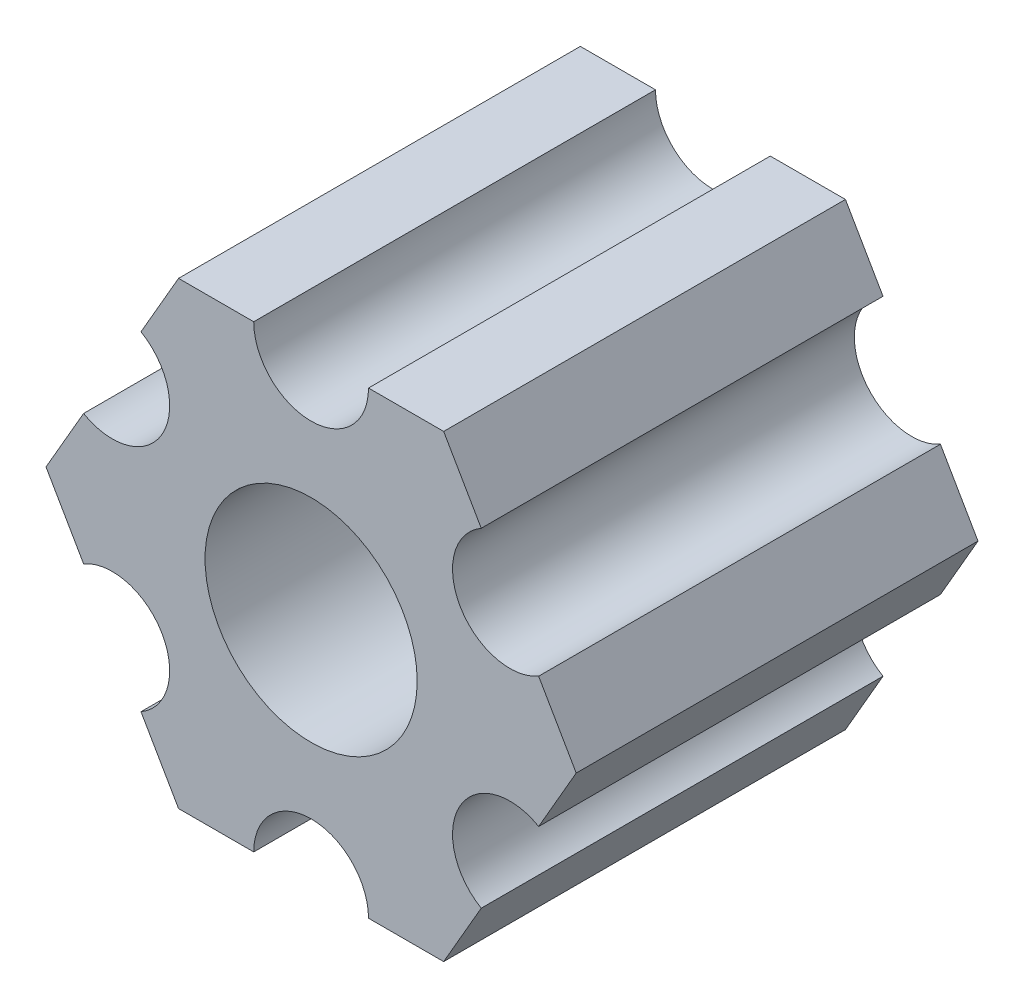
from build123d import *

# Parameters (mm, degrees)
SKETCH1_R           = 2.9337
BOSS_EXTRUDE1_DEPTH = 15.875
CUT_EXTRUDE1_DEPTH  = 4.7625


with BuildPart() as part:
    # Sketch1 → Boss-Extrude1 (new body)
    with BuildSketch(Plane(origin=(0, 0, 0), x_dir=(-1, 0, 0), z_dir=(0, 0, -1))):
        with BuildLine():
            Line((-4.70551159, -4.549815043), (-3.666174521, -6.349999904))
            Line((-3.666174521, -6.349999904), (-1.587500385, -6.349999904))
            ThreePointArc((-1.587500385, -6.349999904), (-3.85e-07, -4.762499904), (1.587499615, -6.349999904))
            Line((1.587499615, -6.349999904), (3.666173825, -6.349999904))
            Line((3.666173825, -6.349999904), (4.705510942, -4.54981524))
            ThreePointArc((4.705510942, -4.54981524), (4.124445629, -2.381249907), (6.293010962, -1.800184594))
            Line((6.293010962, -1.800184594), (7.332348079, 7e-08))
            Line((7.332348079, 7e-08), (6.293011217, 1.800184685))
            ThreePointArc((6.293011217, 1.800184685), (4.124445939, 2.381250203), (4.705511457, 4.549815481))
            Line((4.705511457, 4.549815481), (3.666174521, 6.350000222))
            Line((3.666174521, 6.350000222), (1.587500385, 6.350000222))
            ThreePointArc((1.587500385, 6.350000222), (3.85e-07, 4.762500222), (-1.587499615, 6.350000222))
            Line((-1.587499615, 6.350000222), (-3.666173825, 6.350000222))
            Line((-3.666173825, 6.350000222), (-4.705511038, 4.549815614))
            ThreePointArc((-4.705511038, 4.549815614), (-4.124445841, 2.38125025), (-6.293011205, 1.800185053))
            Line((-6.293011205, 1.800185053), (-7.332348419, 4.44e-07))
            Line((-7.332348419, 4.44e-07), (-6.293011423, -1.80018429))
            ThreePointArc((-6.293011423, -1.80018429), (-4.12444613, -2.38124975), (-4.70551159, -4.549815043))
        make_face()
        Circle(SKETCH1_R, mode=Mode.SUBTRACT)
    extrude(amount=-BOSS_EXTRUDE1_DEPTH)

    # Sketch3 → Cut-Extrude1 (cut)
    with BuildSketch(Plane.XY.offset(15.875)):
        with BuildLine():
            Line((-4.705511457, 4.549815481), (-3.666174521, 6.350000222))
            Line((-3.666174521, 6.350000222), (-1.587500385, 6.350000222))
            ThreePointArc((-1.587500385, 6.350000222), (-3.85e-07, 4.762500222), (1.587499615, 6.350000222))
            Line((1.587499615, 6.350000222), (3.666173825, 6.350000222))
            Line((3.666173825, 6.350000222), (4.705511038, 4.549815614))
            ThreePointArc((4.705511038, 4.549815614), (4.124445841, 2.38125025), (6.293011205, 1.800185053))
            Line((6.293011205, 1.800185053), (7.332348419, 4.44e-07))
            Line((7.332348419, 4.44e-07), (6.293011423, -1.80018429))
            ThreePointArc((6.293011423, -1.80018429), (4.12444613, -2.38124975), (4.70551159, -4.549815043))
            Line((4.70551159, -4.549815043), (3.666174521, -6.349999904))
            Line((3.666174521, -6.349999904), (1.587500385, -6.349999904))
            ThreePointArc((1.587500385, -6.349999904), (3.85e-07, -4.762499904), (-1.587499615, -6.349999904))
            Line((-1.587499615, -6.349999904), (-3.666173825, -6.349999904))
            Line((-3.666173825, -6.349999904), (-4.705510942, -4.54981524))
            ThreePointArc((-4.705510942, -4.54981524), (-4.124445629, -2.381249907), (-6.293010962, -1.800184594))
            Line((-6.293010962, -1.800184594), (-7.332348079, 7e-08))
            Line((-7.332348079, 7e-08), (-6.293011217, 1.800184685))
            ThreePointArc((-6.293011217, 1.800184685), (-4.124445939, 2.381250203), (-4.705511457, 4.549815481))
        make_face()
    extrude(amount=-CUT_EXTRUDE1_DEPTH, mode=Mode.SUBTRACT)


solid = part.part
